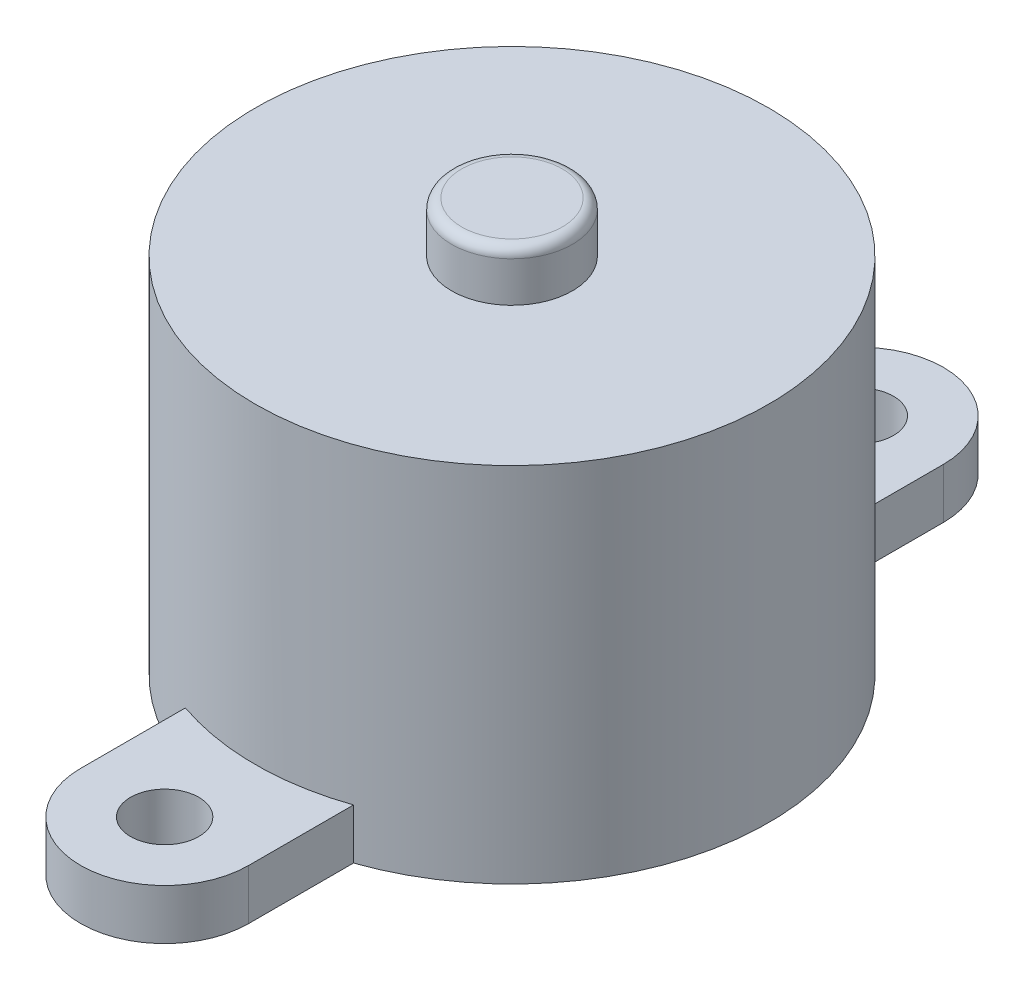
from build123d import *

# Parameters (mm, degrees)
SKETCH1_R           = 12.75
BOSS_EXTRUDE1_DEPTH = 18
SKETCH2_R           = 3
BOSS_EXTRUDE2_DEPTH = 2.5
FILLET1_R           = 0.5
SKETCH3_R           = 1.69339008
BOSS_EXTRUDE3_DEPTH = 2.5


with BuildPart() as part:
    # Sketch1 → Boss-Extrude1 (new body)
    with BuildSketch(Plane(origin=(0, 0, 0), x_dir=(1, 0, 0), z_dir=(0, 1, 0))):
        Circle(SKETCH1_R)
    extrude(amount=BOSS_EXTRUDE1_DEPTH)

    # Sketch2 → Boss-Extrude2 (add)
    with BuildSketch(Plane(origin=(0, 18, 0), x_dir=(1, 0, 0), z_dir=(0, 1, 0))):
        Circle(SKETCH2_R)
    extrude(amount=BOSS_EXTRUDE2_DEPTH)

    # Fillet1
    fillet1_edges = [part.edges().sort_by_distance(p)[0] for p in [
        (-3, 20.5, 0),
    ]]
    fillet(fillet1_edges, radius=FILLET1_R)

    # Sketch3 → Boss-Extrude3 (add)
    with BuildSketch(Plane(origin=(0, 0, 0), x_dir=(1, 0, 0), z_dir=(0, 1, 0))):
        with BuildLine():
            Line((4.175, 12.047069146), (4.175, 17.252375634))
            ThreePointArc((4.175, 17.252375634), (0, 21.427375634), (-4.175, 17.252375634))
            Line((-4.175, 17.252375634), (-4.175, 12.047069146))
            Line((-4.175, 12.047069146), (4.175, 12.047069146))
        make_face()
        with Locations((0, 17.252375634)):
            Circle(SKETCH3_R, mode=Mode.SUBTRACT)
    boss_extrude3 = extrude(amount=BOSS_EXTRUDE3_DEPTH)

    # Mirror1: Boss-Extrude3 across plane
    add(boss_extrude3.mirror(Plane.XY))


solid = part.part
